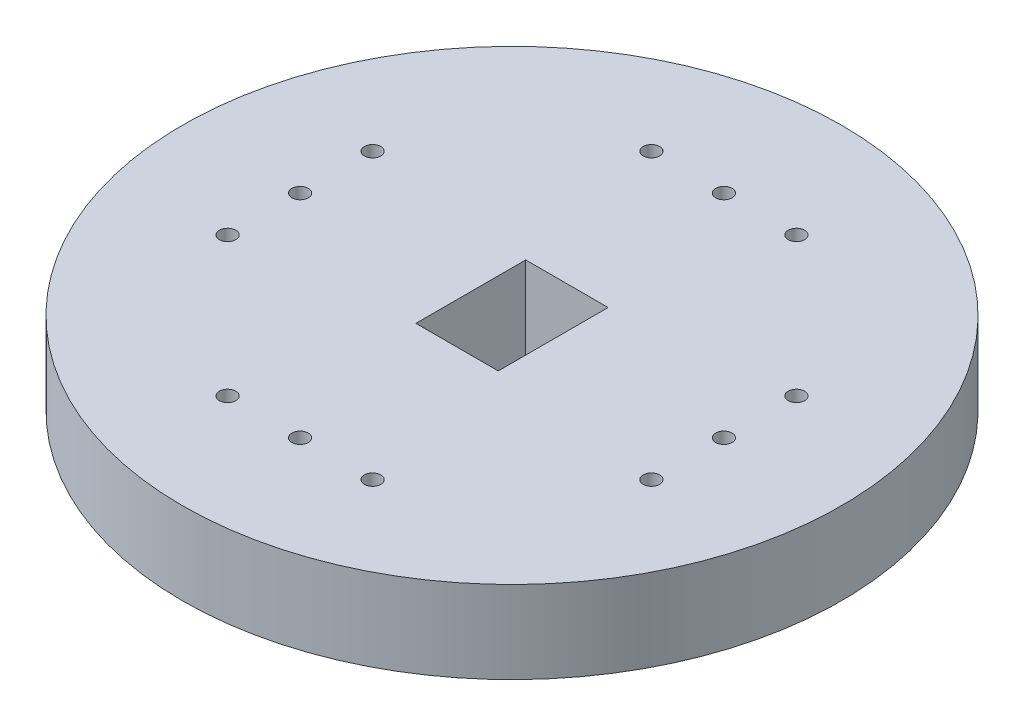
from build123d import *

# Parameters (mm, degrees)
X_Z_SEVO_MOUNT_SKETCH_R            = 12.7
X_Z_SERVO_MOUNT_DEPTH              = 3.175
BASE_MOUNT_SKETCH_W                = 3.175
BASE_MOUNT_SKETCH_H                = 4.233333334
BASE_MOUNT_DEPTH                   = 4.175
SERVO_HORN_MOUNTING_HOLES_SKETCH_R = 0.3175
SERVO_HORN_MOUNT_HOLES_DEPTH       = 4.175


with BuildPart() as part:
    # X-Z Sevo Mount Sketch → X-Z Servo Mount (new body)
    with BuildSketch(Plane(origin=(0, 0, 0), x_dir=(1, 0, 0), z_dir=(0, 1, 0))):
        Circle(X_Z_SEVO_MOUNT_SKETCH_R)
    extrude(amount=X_Z_SERVO_MOUNT_DEPTH)

    # Base Mount Sketch → Base Mount (cut, through all)
    with BuildSketch(Plane(origin=(0, 3.175, 0), x_dir=(1, 0, 0), z_dir=(0, 1, 0))):
        Rectangle(BASE_MOUNT_SKETCH_W, BASE_MOUNT_SKETCH_H)
    extrude(amount=-BASE_MOUNT_DEPTH, mode=Mode.SUBTRACT)

    # Servo Horn Mounting Holes Sketch → Servo Horn Mount Holes (cut, through all)
    with BuildSketch(Plane.XZ):
        with Locations((0, 8.1661)):
            Circle(SERVO_HORN_MOUNTING_HOLES_SKETCH_R)
        with Locations((2.794, 8.1661)):
            Circle(SERVO_HORN_MOUNTING_HOLES_SKETCH_R)
        with Locations((-2.794, 8.1661)):
            Circle(SERVO_HORN_MOUNTING_HOLES_SKETCH_R)
        with Locations((2.794, -8.1661)):
            Circle(SERVO_HORN_MOUNTING_HOLES_SKETCH_R)
        with Locations((0, -8.1661)):
            Circle(SERVO_HORN_MOUNTING_HOLES_SKETCH_R)
        with Locations((-2.794, -8.1661)):
            Circle(SERVO_HORN_MOUNTING_HOLES_SKETCH_R)
        with Locations((8.1661, 0)):
            Circle(SERVO_HORN_MOUNTING_HOLES_SKETCH_R)
        with Locations((8.1661, 2.794)):
            Circle(SERVO_HORN_MOUNTING_HOLES_SKETCH_R)
        with Locations((8.1661, -2.794)):
            Circle(SERVO_HORN_MOUNTING_HOLES_SKETCH_R)
        with Locations((-8.1661, -2.794)):
            Circle(SERVO_HORN_MOUNTING_HOLES_SKETCH_R)
        with Locations((-8.1661, 2.794)):
            Circle(SERVO_HORN_MOUNTING_HOLES_SKETCH_R)
        with Locations((-8.1661, 0)):
            Circle(SERVO_HORN_MOUNTING_HOLES_SKETCH_R)
    extrude(amount=-SERVO_HORN_MOUNT_HOLES_DEPTH, mode=Mode.SUBTRACT)


solid = part.part
